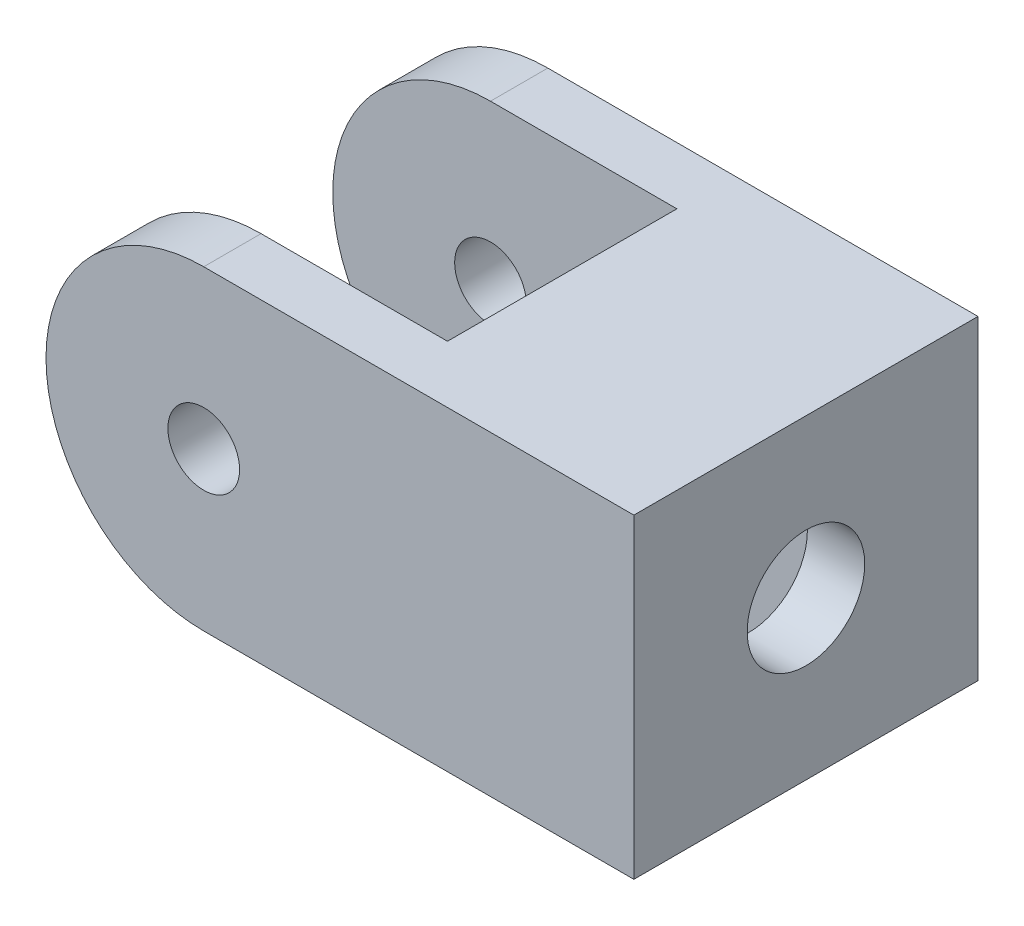
from build123d import *

# Parameters (mm, degrees)
SKETCH1_R           = 2.5
BOSS_EXTRUDE1_DEPTH = 24
SKETCH2_W           = 24
SKETCH2_H           = 16
CUT_EXTRUDE1_DEPTH  = 23
CUT_EXTRUDE2_DEPTH  = 6.8
SKETCH6_R           = 4.1
CUT_EXTRUDE3_DEPTH  = 17


with BuildPart() as part:
    # Sketch1 → Boss-Extrude1 (new body)
    with BuildSketch(Plane.XY):
        with BuildLine():
            Line((0, 11), (30, 11))
            Line((30, 11), (30, -11))
            Line((30, -11), (0, -11))
            ThreePointArc((0, -11), (-11, 0), (0, 11))
        make_face()
        Circle(SKETCH1_R, mode=Mode.SUBTRACT)
    extrude(amount=BOSS_EXTRUDE1_DEPTH)

    # Sketch2 → Cut-Extrude1 (cut, through all)
    with BuildSketch(Plane(origin=(0, 11, 0), x_dir=(1, 0, 0), z_dir=(0, 1, 0))):
        with Locations((1, -12)):
            Rectangle(SKETCH2_W, SKETCH2_H)
    extrude(amount=-CUT_EXTRUDE1_DEPTH, mode=Mode.SUBTRACT)

    # Sketch4 → Cut-Extrude2 (cut)
    with BuildSketch(Plane(origin=(26, 0, 0), x_dir=(0, 0, -1), z_dir=(1, 0, 0))):
        Polygon((-18.5, 3.75277675), (-18.5, -11), (-5.5, -11), (-5.5, 3.75277675), (-12, 7.505553499), align=None)
    extrude(amount=-CUT_EXTRUDE2_DEPTH, mode=Mode.SUBTRACT)

    # Sketch6 → Cut-Extrude3 (cut)
    with BuildSketch(Plane(origin=(30, 0, 0), x_dir=(0, 0, -1), z_dir=(1, 0, 0))):
        with Locations((-12, 0)):
            Circle(SKETCH6_R)
    extrude(amount=-CUT_EXTRUDE3_DEPTH, mode=Mode.SUBTRACT)


solid = part.part
